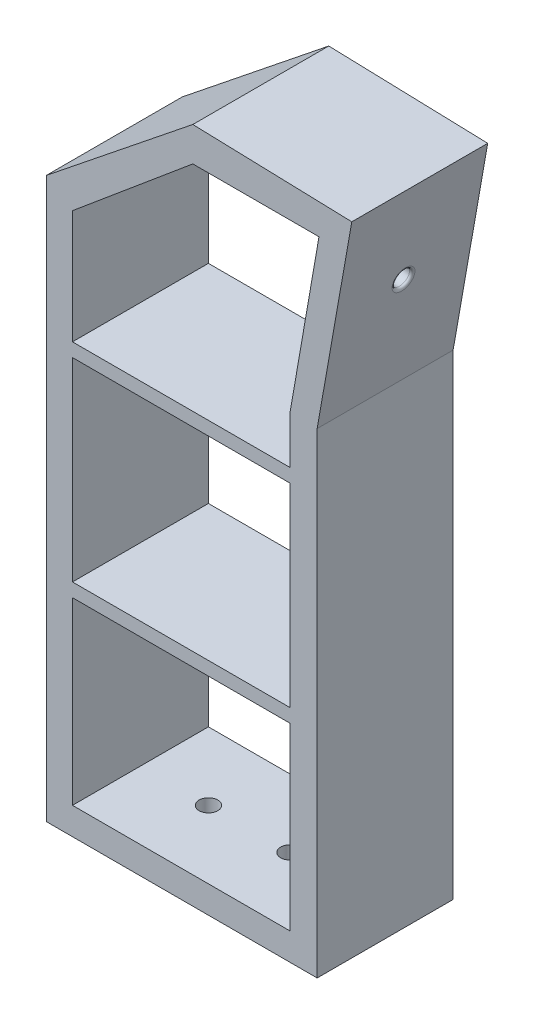
from build123d import *

# Parameters (mm, degrees)
BOSS_EXTRUDE1_DEPTH = 50
SKETCH10_R          = 3.425
CUT_EXTRUDE5_DEPTH  = 10
SKETCH11_W          = 80
SKETCH11_H          = 5
BOSS_EXTRUDE3_DEPTH = 50
SKETCH14_R          = 3.15
CUT_EXTRUDE6_DEPTH  = 10
FILLET1_R           = 1


with BuildPart() as part:
    # Sketch2 → Boss-Extrude1 (new body)
    with BuildSketch(Plane.XY):
        Polygon((-40.506485759, 0), (59.130974018, 0), (59.130974018, 175), (71.870010435, 247.246665631), (13.397315769, 249.004598584), (-40.506485759, 205.829132158), align=None)
        Polygon((59.130974018, 232.587704831), (59.8009874, 236.446158122), (42.633663102, 236.446158122), (13.397315769, 236.446158122), (6.25157797, 230.468732297), (-30.869025982, 199.417263157), (-30.869025982, 107.989726368), (-30.869025982, 10), (0, 10), (49.130974018, 10), (49.130974018, 87.5), (49.130974018, 175), align=None, mode=Mode.SUBTRACT)
    extrude(amount=BOSS_EXTRUDE1_DEPTH)

    # Sketch10 → Cut-Extrude5 (cut)
    with BuildSketch(Plane(origin=(0, 10, 0), x_dir=(1, 0, 0), z_dir=(0, 1, 0))):
        with Locations((-5.851287133, -25)):
            Circle(SKETCH10_R)
        with Locations((24.130974018, -25)):
            Circle(SKETCH10_R)
    extrude(amount=-CUT_EXTRUDE5_DEPTH, mode=Mode.SUBTRACT)

    # Sketch11 → Boss-Extrude3 (add)
    with BuildSketch(Plane.XY.offset(50)):
        with Locations((9.130974018, 155.135730726)):
            Rectangle(SKETCH11_W, SKETCH11_H)
        with Locations((9.130974018, 78.651297101)):
            Rectangle(SKETCH11_W, SKETCH11_H)
    extrude(amount=-BOSS_EXTRUDE3_DEPTH)

    # Sketch14 → Cut-Extrude6 (cut)
    with BuildSketch(Plane(origin=(27.42119444, -4.835096423, 0), x_dir=(0, 0, -1), z_dir=(0.984807753, -0.173648178, 0))):
        with Locations((-25, 221.609342659)):
            Circle(SKETCH14_R)
    extrude(amount=-CUT_EXTRUDE6_DEPTH, mode=Mode.SUBTRACT)

    # Fillet1
    fillet1_edges = [part.edges().sort_by_distance(p)[0] for p in [
        (65.903252947, 213.407502367, 28.15),
    ]]
    fillet(fillet1_edges, radius=FILLET1_R)


solid = part.part
